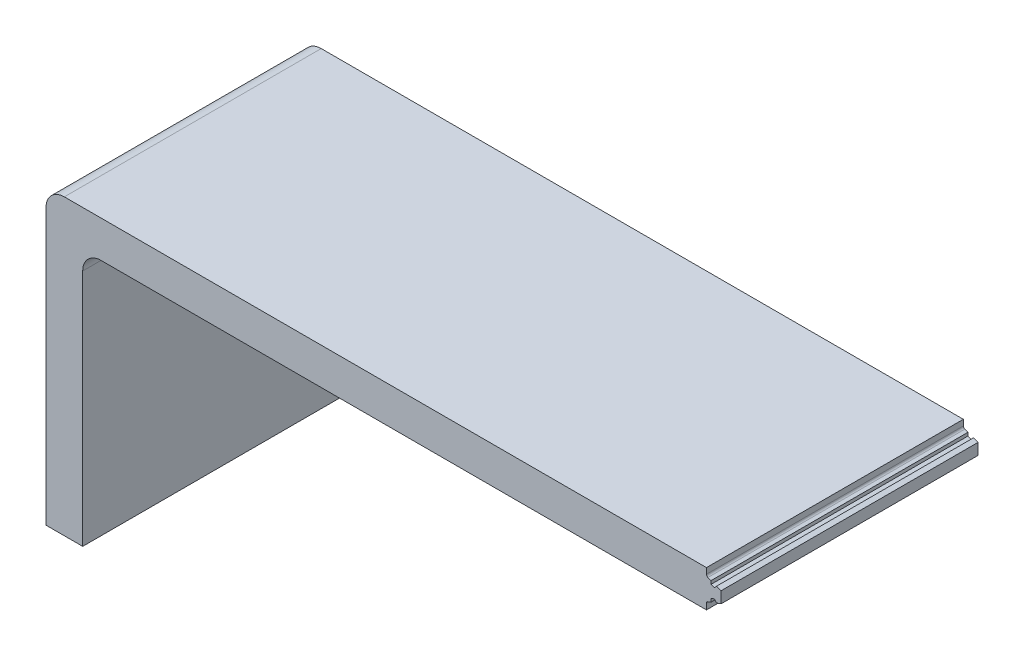
from build123d import *

# Parameters (mm, degrees)
BOSS_EXTRUDE2_DEPTH = 88.9
CUT_EXTRUDE3_DEPTH  = 89.9
FILLET2_R           = 6.35
FILLET4_R           = 0.762


with BuildPart() as part:
    # Sketch1 → Boss-Extrude2 (new body)
    with BuildSketch(Plane.XY):
        Polygon((0, 0), (0, 101.6), (233.68, 101.6), (233.68, 88.9), (12.7, 88.9), (12.7, 0), align=None)
    extrude(amount=BOSS_EXTRUDE2_DEPTH)

    # Sketch8 → Cut-Extrude3 (cut, through all)
    with BuildSketch(Plane.XY.offset(88.9)):
        Polygon((228.6, 101.6), (233.68, 101.6), (233.68, 97.21103121), (232.101530561, 97.785547072), (231.371879071, 96.91598223), (230.178469436, 97.350347792), (230.178469436, 98.485484045), (228.6, 99.059999906), align=None)
        Polygon((228.6, 88.9), (233.68, 88.9), (233.68, 93.28896879), (232.101530561, 92.714452928), (231.371879071, 93.58401777), (230.178469436, 93.149652208), (230.178469436, 92.014515955), (228.6, 91.440000094), align=None)
    extrude(amount=-CUT_EXTRUDE3_DEPTH, mode=Mode.SUBTRACT)

    # Fillet2
    fillet2_edges = [part.edges().sort_by_distance(p)[0] for p in [
        (0, 101.6, 44.45),
        (12.7, 88.9, 44.45),
    ]]
    fillet(fillet2_edges, radius=FILLET2_R)

    # Fillet4
    fillet4_edges = [part.edges().sort_by_distance(p)[0] for p in [
        (228.6, 91.440000094, 44.45),
        (228.6, 99.059999906, 44.45),
    ]]
    fillet(fillet4_edges, radius=FILLET4_R)


solid = part.part
